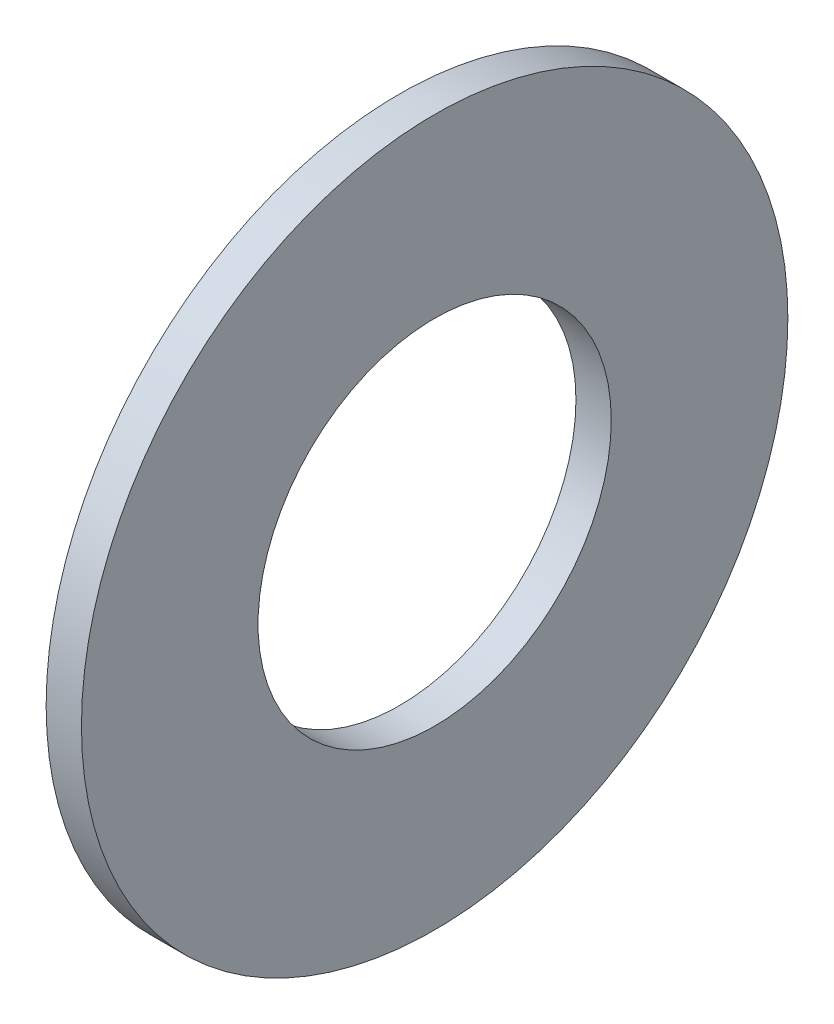
from build123d import *

# Parameters (mm, degrees)
SKETCH1_R           = 20
SKETCH1_R_2         = 10
BOSS_EXTRUDE1_DEPTH = 2


with BuildPart() as part:
    # Sketch1 → Boss-Extrude1 (new body)
    with BuildSketch(Plane(origin=(0, 0, 0), x_dir=(0, 0, -1), z_dir=(1, 0, 0))):
        Circle(SKETCH1_R)
        Circle(SKETCH1_R_2, mode=Mode.SUBTRACT)
    extrude(amount=BOSS_EXTRUDE1_DEPTH)


solid = part.part
